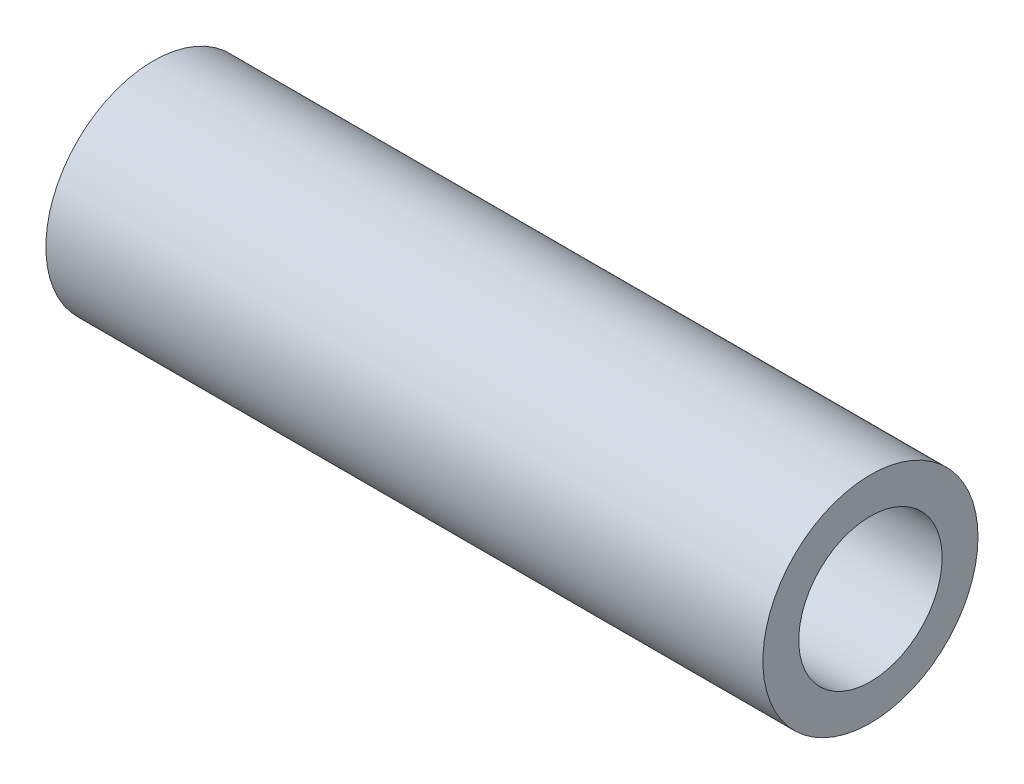
from build123d import *

# Parameters (mm, degrees)
SKETCH1_R             = 1.5
SKETCH1_R_2           = 1
EXTRUDE_9811T16_DEPTH = 10


with BuildPart() as part:
    # Sketch1 → Extrude 9811T16 (new body)
    with BuildSketch(Plane(origin=(0, 0, 0), x_dir=(0, 0, -1), z_dir=(1, 0, 0))):
        Circle(SKETCH1_R)
        Circle(SKETCH1_R_2, mode=Mode.SUBTRACT)
    extrude(amount=EXTRUDE_9811T16_DEPTH)


solid = part.part
